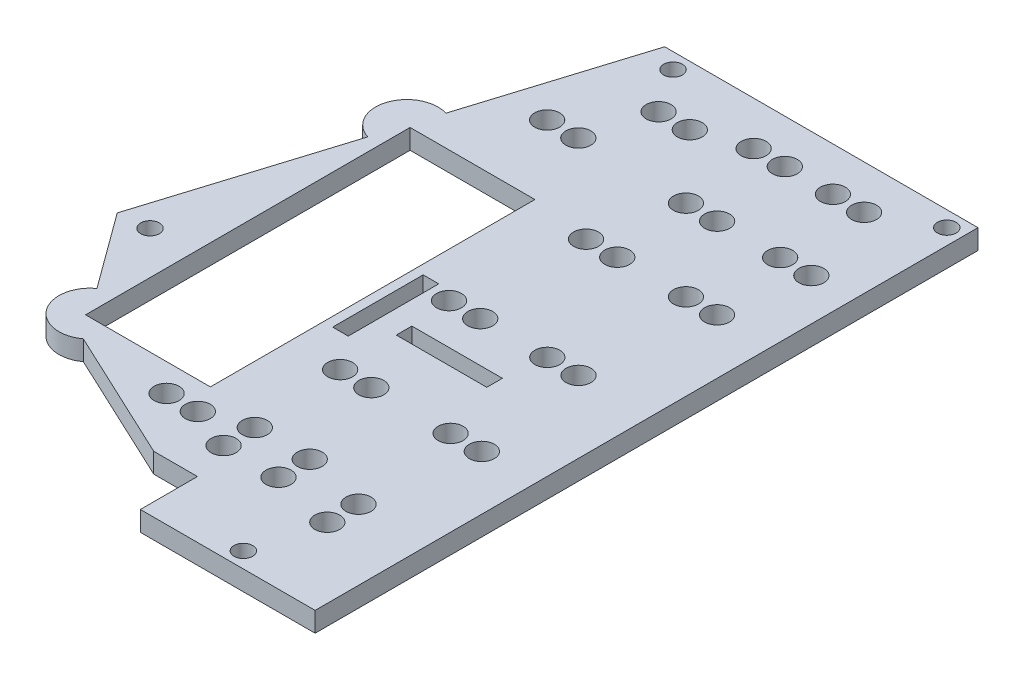
from build123d import *

# Parameters (mm, degrees)
SKETCH1_R           = 1.5
SKETCH1_R_2         = 2
SKETCH1_W           = 2.5
SKETCH1_H           = 14.5
SKETCH1_W_2         = 14.5
SKETCH1_H_2         = 2.5
SKETCH1_W_3         = 20
SKETCH1_H_3         = 52
BOSS_EXTRUDE1_DEPTH = 3.175


with BuildPart() as part:
    # Sketch1 → Boss-Extrude1 (new body)
    with BuildSketch(Plane(origin=(0, 0, 0), x_dir=(1, 0, 0), z_dir=(0, 1, 0))):
        with BuildLine():
            Line((-22.047586286, 28.724844999), (28.152410312, 28.724844999))
            Line((28.152410312, 28.724844999), (28.152410312, -68.278843574))
            Line((28.152410312, -68.278843574), (28.152410312, -77.482069575))
            Line((28.152410312, -77.482069575), (0.152410312, -77.482069575))
            Line((0.152410312, -77.482069575), (0.152410312, -68.337119167))
            Line((0.152410312, -68.337119167), (-6.847541173, -68.337119167))
            Line((-6.847541173, -68.337119167), (-28.095254294, -58.371916125))
            ThreePointArc((-28.095254294, -58.371916125), (-35.084160474, -57.28326894), (-33.991325412, -50.295016382))
            Line((-33.991325412, -50.295016382), (-42.847532209, -38.188499756))
            Line((-42.847532209, -38.188499756), (-33.328350902, -7.56533069))
            ThreePointArc((-33.328350902, -7.56533069), (-36.624195189, -1.304825925), (-30.359969494, 1.9839407))
            Line((-30.359969494, 1.9839407), (-22.047586286, 28.724844999))
        make_face()
        with Locations((25.652410312, 26.224844999)):
            Circle(SKETCH1_R, mode=Mode.SUBTRACT)
        with Locations((-38.087063045, -37.694179546)):
            Circle(SKETCH1_R, mode=Mode.SUBTRACT)
        with Locations((-18.207043121, 26.221156426)):
            Circle(SKETCH1_R, mode=Mode.SUBTRACT)
        with Locations((16.902410312, 21.724844999)):
            Circle(SKETCH1_R_2, mode=Mode.SUBTRACT)
        with Locations((11.902410312, 21.724844999)):
            Circle(SKETCH1_R_2, mode=Mode.SUBTRACT)
        with Locations((4.202410312, 21.724844999)):
            Circle(SKETCH1_R_2, mode=Mode.SUBTRACT)
        with Locations((-0.797589688, 21.724844999)):
            Circle(SKETCH1_R_2, mode=Mode.SUBTRACT)
        with Locations((-8.518099948, 19.221156426)):
            Circle(SKETCH1_R_2, mode=Mode.SUBTRACT)
        with Locations((-13.518099948, 19.221156426)):
            Circle(SKETCH1_R_2, mode=Mode.SUBTRACT)
        with Locations((-16.301455712, 9.146912193)):
            Circle(SKETCH1_R_2, mode=Mode.SUBTRACT)
        with Locations((-21.301455712, 9.146912193)):
            Circle(SKETCH1_R_2, mode=Mode.SUBTRACT)
        with Locations((-2.047589688, -61.948843574)):
            Circle(SKETCH1_R_2, mode=Mode.SUBTRACT)
        with Locations((-2.047589688, -56.948843574)):
            Circle(SKETCH1_R_2, mode=Mode.SUBTRACT)
        with Locations((6.752410312, -61.948843574)):
            Circle(SKETCH1_R_2, mode=Mode.SUBTRACT)
        with Locations((6.752410312, -56.948843574)):
            Circle(SKETCH1_R_2, mode=Mode.SUBTRACT)
        with Locations((-8.847589688, -59.278843574)):
            Circle(SKETCH1_R_2, mode=Mode.SUBTRACT)
        with Locations((-13.847589688, -59.278843574)):
            Circle(SKETCH1_R_2, mode=Mode.SUBTRACT)
        with Locations((21.452410312, 8.724844999)):
            Circle(SKETCH1_R_2, mode=Mode.SUBTRACT)
        with Locations((16.452410312, 8.724844999)):
            Circle(SKETCH1_R_2, mode=Mode.SUBTRACT)
        with Locations((6.352410312, 8.724844999)):
            Circle(SKETCH1_R_2, mode=Mode.SUBTRACT)
        with Locations((1.352410312, 8.724844999)):
            Circle(SKETCH1_R_2, mode=Mode.SUBTRACT)
        with Locations((14.352410312, -4.275155001)):
            Circle(SKETCH1_R_2, mode=Mode.SUBTRACT)
        with Locations((19.352410312, -4.275155001)):
            Circle(SKETCH1_R_2, mode=Mode.SUBTRACT)
        with Locations((3.352410312, -4.275155001)):
            Circle(SKETCH1_R_2, mode=Mode.SUBTRACT)
        with Locations((-1.647589688, -4.275155001)):
            Circle(SKETCH1_R_2, mode=Mode.SUBTRACT)
        with Locations((16.652410312, -23.778843574)):
            Circle(SKETCH1_R_2, mode=Mode.SUBTRACT)
        with Locations((11.652410312, -23.778843574)):
            Circle(SKETCH1_R_2, mode=Mode.SUBTRACT)
        with Locations((0.902410312, -23.778843574)):
            Circle(SKETCH1_R_2, mode=Mode.SUBTRACT)
        with Locations((-4.097589688, -23.778843574)):
            Circle(SKETCH1_R_2, mode=Mode.SUBTRACT)
        with Locations((19.452410312, -42.075155001)):
            Circle(SKETCH1_R_2, mode=Mode.SUBTRACT)
        with Locations((14.452410312, -42.075155001)):
            Circle(SKETCH1_R_2, mode=Mode.SUBTRACT)
        with Locations((1.752410312, -42.075155001)):
            Circle(SKETCH1_R_2, mode=Mode.SUBTRACT)
        with Locations((-3.247589688, -42.075155001)):
            Circle(SKETCH1_R_2, mode=Mode.SUBTRACT)
        with Locations((16.902410312, -59.278843574)):
            Circle(SKETCH1_R_2, mode=Mode.SUBTRACT)
        with Locations((16.902410312, -64.278843574)):
            Circle(SKETCH1_R_2, mode=Mode.SUBTRACT)
        with Locations((14.152410312, -74.982069575)):
            Circle(SKETCH1_R, mode=Mode.SUBTRACT)
        with Locations((-8.497589688, -29.525155001)):
            Rectangle(SKETCH1_W, SKETCH1_H, mode=Mode.SUBTRACT)
        with Locations((3.702410312, -31.528843574)):
            Rectangle(SKETCH1_W_2, SKETCH1_H_2, mode=Mode.SUBTRACT)
        with Locations((-21.247589688, -28.865155001)):
            Rectangle(SKETCH1_W_3, SKETCH1_H_3, mode=Mode.SUBTRACT)
    extrude(amount=BOSS_EXTRUDE1_DEPTH)


solid = part.part
